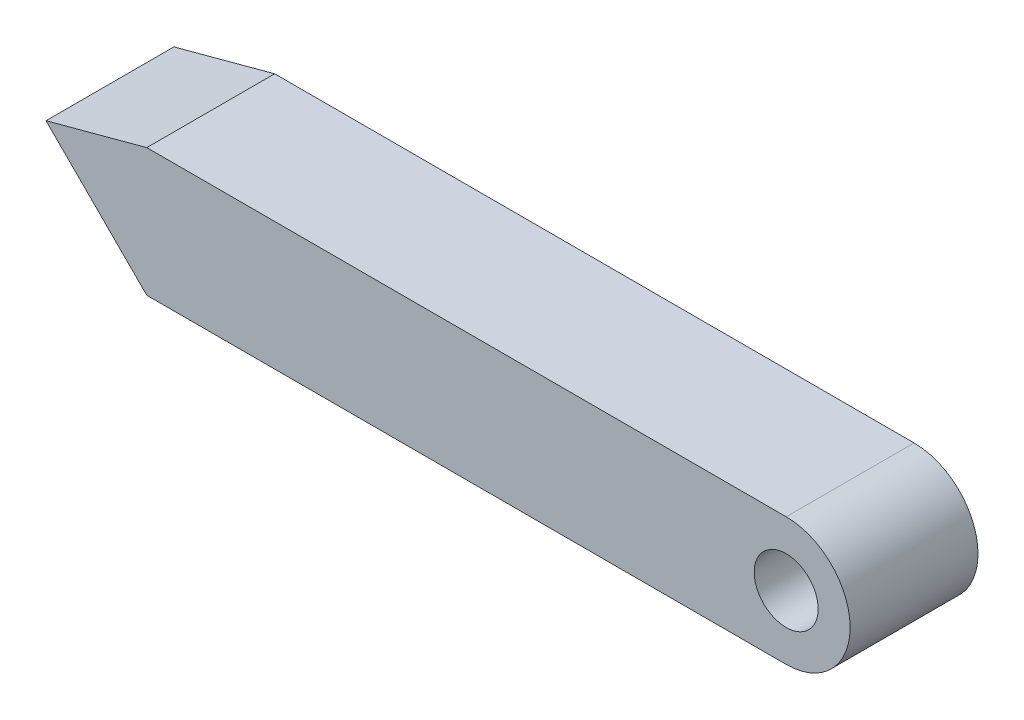
from build123d import *

# Parameters (mm, degrees)
SKETCH1_R           = 2.5
BOSS_EXTRUDE1_DEPTH = 10


with BuildPart() as part:
    # Sketch1 → Boss-Extrude1 (new body)
    with BuildSketch(Plane.XY):
        with BuildLine():
            Line((0, 5), (-50, 5))
            Line((-50, 5), (-57.880486008, 2.880486008))
            Line((-57.880486008, 2.880486008), (-50, -5))
            Line((-50, -5), (0, -5))
            ThreePointArc((0, -5), (5, 0), (0, 5))
        make_face()
        Circle(SKETCH1_R, mode=Mode.SUBTRACT)
    extrude(amount=BOSS_EXTRUDE1_DEPTH)


solid = part.part
